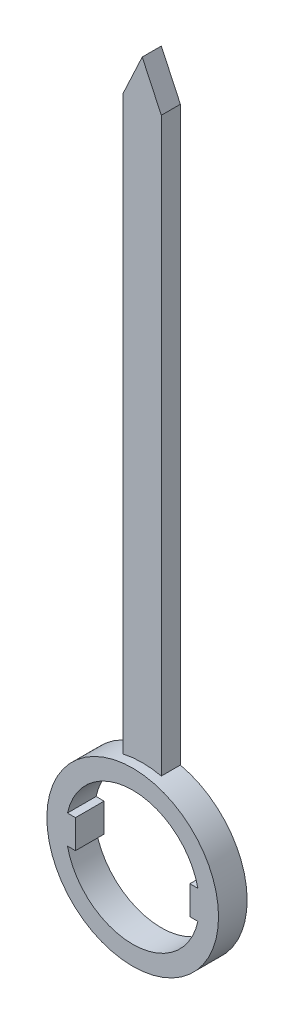
from build123d import *

# Parameters (mm, degrees)
SKETCH1_R           = 9
BOSS_EXTRUDE1_DEPTH = 3
BOSS_EXTRUDE2_DEPTH = 2


with BuildPart() as part:
    # Sketch1 → Boss-Extrude1 (new body)
    with BuildSketch(Plane.XY):
        Circle(SKETCH1_R)
        with BuildLine():
            Line((-6.837397166, -1.5), (-8, -1.5))
            Line((-8, -1.5), (-8, 1.5))
            Line((-8, 1.5), (-6.837397166, 1.5))
            ThreePointArc((-6.837397166, 1.5), (0, 7), (6.837397166, 1.5))
            Line((6.837397166, 1.5), (8, 1.5))
            Line((8, 1.5), (8, -1.5))
            Line((8, -1.5), (6.837397166, -1.5))
            ThreePointArc((6.837397166, -1.5), (0, -7), (-6.837397166, -1.5))
        make_face(mode=Mode.SUBTRACT)
        with BuildLine():
            Line((6, -1.5), (6.837397166, -1.5))
            ThreePointArc((6.837397166, -1.5), (6.959230567, -0.754393744), (7, 0))
            ThreePointArc((7, 0), (6.959230567, 0.754393744), (6.837397166, 1.5))
            Line((6.837397166, 1.5), (6, 1.5))
            Line((6, 1.5), (6, -1.5))
        make_face()
        with BuildLine():
            ThreePointArc((7, 0), (6.959230567, -0.754393744), (6.837397166, -1.5))
            Line((6.837397166, -1.5), (8, -1.5))
            Line((8, -1.5), (8, 1.5))
            Line((8, 1.5), (6.837397166, 1.5))
            ThreePointArc((6.837397166, 1.5), (6.959230567, 0.754393744), (7, 0))
        make_face()
        with BuildLine():
            Line((-8, 1.5), (-8, -1.5))
            Line((-8, -1.5), (-6.837397166, -1.5))
            ThreePointArc((-6.837397166, -1.5), (-7, 0), (-6.837397166, 1.5))
            Line((-6.837397166, 1.5), (-8, 1.5))
        make_face()
        with BuildLine():
            ThreePointArc((-6.837397166, 1.5), (-7, 0), (-6.837397166, -1.5))
            Line((-6.837397166, -1.5), (-6, -1.5))
            Line((-6, -1.5), (-6, 1.5))
            Line((-6, 1.5), (-6.837397166, 1.5))
        make_face()
    extrude(amount=BOSS_EXTRUDE1_DEPTH)

    # Sketch2 → Boss-Extrude2 (add)
    with BuildSketch(Plane(origin=(0, 0, 0), x_dir=(-1, 0, 0), z_dir=(0, 0, -1))):
        with BuildLine():
            Line((-2, 68.774964387), (-2, 8.774964387))
            ThreePointArc((-2, 8.774964387), (0, 9), (2, 8.774964387))
            Line((2, 8.774964387), (2, 68.774964387))
            Line((2, 68.774964387), (0, 73.063978228))
            Line((0, 73.063978228), (-2, 68.774964387))
        make_face()
    extrude(amount=-BOSS_EXTRUDE2_DEPTH)


solid = part.part
